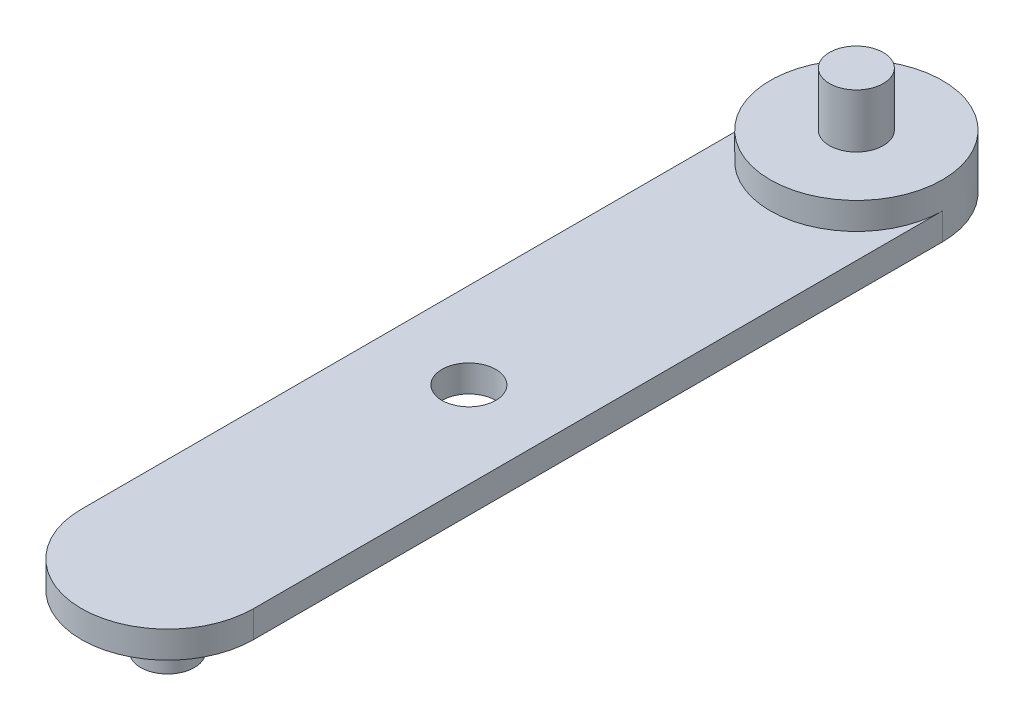
from build123d import *

# Parameters (mm, degrees)
BOSS_EXTRUDE1_DEPTH = 2.5
BOSS_EXTRUDE5_DEPTH = 1.25
SKETCH6_R           = 1.25
BOSS_EXTRUDE6_DEPTH = 2.5
SKETCH7_R           = 1.25
BOSS_EXTRUDE7_DEPTH = 2.5
SKETCH8_R           = 1.25
CUT_EXTRUDE3_DEPTH  = 2.5


with BuildPart() as part:
    # Sketch1 → Boss-Extrude1 (new body)
    with BuildSketch(Plane(origin=(0, 0, 0), x_dir=(1, 0, 0), z_dir=(0, 1, 0))):
        with BuildLine():
            ThreePointArc((4, 32), (0, 36), (-4, 32))
            ThreePointArc((-4, 32), (0, 28), (4, 32))
        make_face()
    extrude(amount=BOSS_EXTRUDE1_DEPTH)

    # Sketch1_4 → Boss-Extrude5 (add)
    with BuildSketch(Plane(origin=(0, 0, 0), x_dir=(1, 0, 0), z_dir=(0, 1, 0))):
        with BuildLine():
            Line((-4, 32), (-4, 0))
            ThreePointArc((-4, 0), (0, -4), (4, 0))
            Line((4, 0), (4, 32))
            ThreePointArc((4, 32), (0, 28), (-4, 32))
        make_face()
    extrude(amount=BOSS_EXTRUDE5_DEPTH)

    # Sketch6 → Boss-Extrude6 (add)
    with BuildSketch(Plane(origin=(0, 2.5, 0), x_dir=(1, 0, 0), z_dir=(0, 1, 0))):
        with Locations((0, 32)):
            Circle(SKETCH6_R)
    extrude(amount=BOSS_EXTRUDE6_DEPTH)

    # Sketch7 → Boss-Extrude7 (add)
    with BuildSketch(Plane.XZ):
        Circle(SKETCH7_R)
    extrude(amount=BOSS_EXTRUDE7_DEPTH)

    # Sketch8 → Cut-Extrude3 (cut)
    with BuildSketch(Plane(origin=(0, 1.25, 0), x_dir=(1, 0, 0), z_dir=(0, 1, 0))):
        with Locations((0, 14)):
            Circle(SKETCH8_R)
    extrude(amount=-CUT_EXTRUDE3_DEPTH, mode=Mode.SUBTRACT)


solid = part.part
